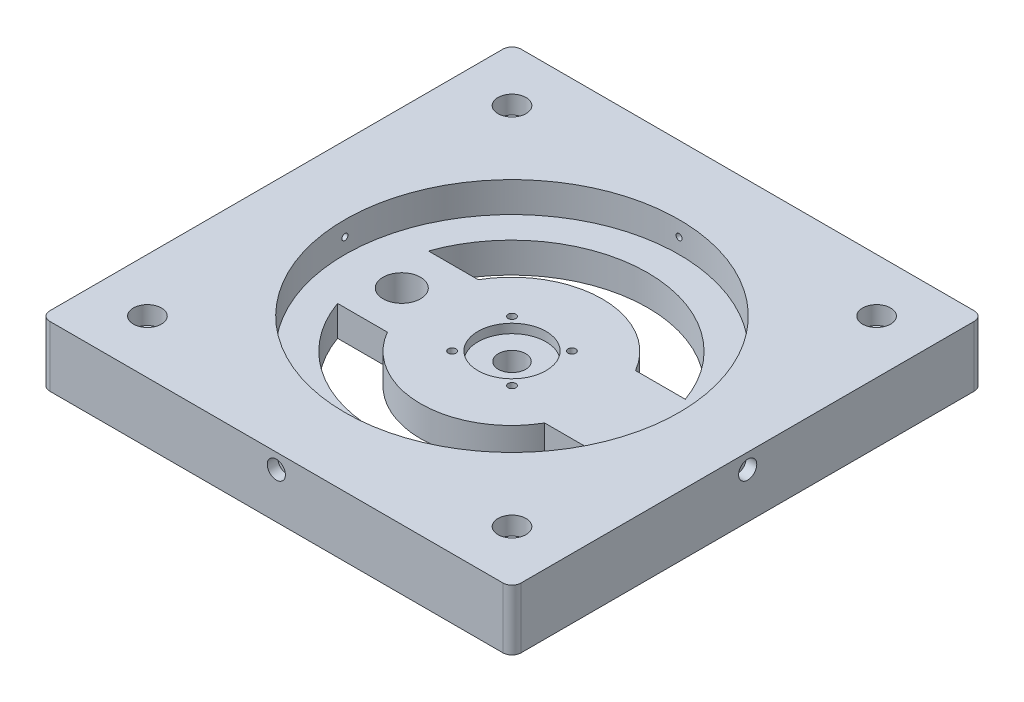
from build123d import *

# Parameters (mm, degrees)
SKETCH1_R           = 2.637642313
SKETCH1_R_2         = 73
BOSS_EXTRUDE1_DEPTH = 20
SKETCH7_R           = 73
SKETCH7_R_2         = 52.25
BOSS_EXTRUDE2_DEPTH = 10
SKETCH8_R           = 73
BOSS_EXTRUDE3_DEPTH = 10
SKETCH9_R           = 11.25
CUT_EXTRUDE1_DEPTH  = 3
SKETCH10_R          = 4.5
CUT_EXTRUDE2_DEPTH  = 89
SKETCH11_R          = 55.2
SKETCH11_R_2        = 52.25
CUT_EXTRUDE3_DEPTH  = 10
SKETCH12_R          = 1
CUT_EXTRUDE4_DEPTH  = 224
SKETCH13_R          = 1
CUT_EXTRUDE5_DEPTH  = 224
SKETCH14_R          = 2.637642313
SKETCH14_R_2        = 1.637642313
BOSS_EXTRUDE4_DEPTH = 20
SKETCH16_R          = 4.637642313
SKETCH16_R_2        = 1.637642313
CUT_EXTRUDE7_DEPTH  = 6
CUT_EXTRUDE11_DEPTH = 15.5
SKETCH19_R          = 6.2
CUT_EXTRUDE12_DEPTH = 144
SKETCH20_R          = 3
SKETCH20_R_2        = 1
CUT_EXTRUDE13_DEPTH = 3.5
SKETCH21_R          = 3
CUT_EXTRUDE14_DEPTH = 3.5
SKETCH22_R          = 3
SKETCH22_R_2        = 1
CUT_EXTRUDE15_DEPTH = 3.5
SKETCH23_R          = 3
CUT_EXTRUDE16_DEPTH = 3.5


with BuildPart() as part:
    # Sketch1 → Boss-Extrude1 (new body)
    with BuildSketch(Plane(origin=(0, 0, 0), x_dir=(1, 0, 0), z_dir=(0, 1, 0))):
        with BuildLine():
            Line((77.460838348, -75.098177713), (77.460838348, 74.577424045))
            ThreePointArc((77.460838348, 74.577424045), (76.578174547, 76.708362964), (74.447235628, 77.591026765))
            Line((74.447235628, 77.591026765), (-75.22836613, 77.591026765))
            ThreePointArc((-75.22836613, 77.591026765), (-77.359305049, 76.708362964), (-78.24196885, 74.577424045))
            Line((-78.24196885, 74.577424045), (-78.24196885, -75.098177713))
            ThreePointArc((-78.24196885, -75.098177713), (-77.359305049, -77.229116632), (-75.22836613, -78.111780433))
            Line((-75.22836613, -78.111780433), (74.447235628, -78.111780433))
            ThreePointArc((74.447235628, -78.111780433), (76.578174547, -77.229116632), (77.460838348, -75.098177713))
        make_face()
        with Locations((-60.604326536, -60.47413812)):
            Circle(SKETCH1_R, mode=Mode.SUBTRACT)
        with Locations((-60.604326536, 59.953384452)):
            Circle(SKETCH1_R, mode=Mode.SUBTRACT)
        with Locations((59.823196035, 59.953384452)):
            Circle(SKETCH1_R, mode=Mode.SUBTRACT)
        with Locations((59.823196035, -60.47413812)):
            Circle(SKETCH1_R, mode=Mode.SUBTRACT)
        with Locations((-0.390565251, -0.260376834)):
            Circle(SKETCH1_R_2, mode=Mode.SUBTRACT)
    extrude(amount=BOSS_EXTRUDE1_DEPTH)

    # Sketch7 → Boss-Extrude2 (add)
    with BuildSketch(Plane(origin=(0, 20, 0), x_dir=(1, 0, 0), z_dir=(0, 1, 0))):
        with Locations((-0.390565251, -0.260376834)):
            Circle(SKETCH7_R)
        with Locations((-0.390565251, -0.260376834)):
            Circle(SKETCH7_R_2, mode=Mode.SUBTRACT)
    extrude(amount=-BOSS_EXTRUDE2_DEPTH)

    # Sketch8 → Boss-Extrude3 (add)
    with BuildSketch(Plane.XZ.offset(-10)):
        with Locations((-0.390565251, 0.260376834)):
            Circle(SKETCH8_R)
    extrude(amount=BOSS_EXTRUDE3_DEPTH)

    # Sketch9 → Cut-Extrude1 (cut)
    with BuildSketch(Plane(origin=(0, 10, 0), x_dir=(1, 0, 0), z_dir=(0, 1, 0))):
        with Locations((-0.390565251, -0.260376834)):
            Circle(SKETCH9_R)
    extrude(amount=-CUT_EXTRUDE1_DEPTH, mode=Mode.SUBTRACT)

    # Sketch10 → Cut-Extrude2 (cut)
    with BuildSketch(Plane(origin=(0, 10, 0), x_dir=(1, 0, 0), z_dir=(0, 1, 0))):
        with Locations((-0.390565251, -0.260376834)):
            Circle(SKETCH10_R)
        with BuildLine():
            ThreePointArc((9.508929686, -11.424371771), (10.773429686, -10.159871771), (9.508929686, -8.895371771))
            ThreePointArc((9.508929686, -8.895371771), (8.244429686, -10.159871771), (9.508929686, -11.424371771))
        make_face()
        with BuildLine():
            ThreePointArc((-10.290060188, -11.424371771), (-9.025560188, -10.159871771), (-10.290060188, -8.895371771))
            ThreePointArc((-10.290060188, -8.895371771), (-11.554560188, -10.159871771), (-10.290060188, -11.424371771))
        make_face()
        with BuildLine():
            ThreePointArc((-10.290060188, 10.903618103), (-11.554560188, 9.639118103), (-10.290060188, 8.374618103))
            ThreePointArc((-10.290060188, 8.374618103), (-9.025560188, 9.639118103), (-10.290060188, 10.903618103))
        make_face()
        with BuildLine():
            ThreePointArc((9.508929686, 10.903618103), (8.244429686, 9.639118103), (9.508929686, 8.374618103))
            ThreePointArc((9.508929686, 8.374618103), (10.773429686, 9.639118103), (9.508929686, 10.903618103))
        make_face()
    extrude(amount=-CUT_EXTRUDE2_DEPTH, mode=Mode.SUBTRACT)

    # Sketch11 → Cut-Extrude3 (cut)
    with BuildSketch(Plane(origin=(0, 20, 0), x_dir=(1, 0, 0), z_dir=(0, 1, 0))):
        with Locations((-0.390565251, -0.260376834)):
            Circle(SKETCH11_R)
        with Locations((-0.390565251, -0.260376834)):
            Circle(SKETCH11_R_2, mode=Mode.SUBTRACT)
    extrude(amount=-CUT_EXTRUDE3_DEPTH, mode=Mode.SUBTRACT)

    # Sketch12 → Cut-Extrude4 (cut)
    with BuildSketch(Plane(origin=(0, 0, -77.591026765), x_dir=(-1, 0, 0), z_dir=(0, 0, -1))):
        with Locations((0.390565251, 15)):
            Circle(SKETCH12_R)
    extrude(amount=-CUT_EXTRUDE4_DEPTH, mode=Mode.SUBTRACT)

    # Sketch13 → Cut-Extrude5 (cut)
    with BuildSketch(Plane.ZY.offset(78.24196885)):
        with Locations((0.260376834, 15)):
            Circle(SKETCH13_R)
    extrude(amount=-CUT_EXTRUDE5_DEPTH, mode=Mode.SUBTRACT)

    # Sketch14 → Boss-Extrude4 (add)
    with BuildSketch(Plane(origin=(0, 20, 0), x_dir=(1, 0, 0), z_dir=(0, 1, 0))):
        with Locations((59.823196035, -60.47413812)):
            Circle(SKETCH14_R)
        with Locations((59.823196035, -60.47413812)):
            Circle(SKETCH14_R_2, mode=Mode.SUBTRACT)
        with Locations((-60.604326536, -60.47413812)):
            Circle(SKETCH14_R)
        with Locations((-60.604326536, -60.47413812)):
            Circle(SKETCH14_R_2, mode=Mode.SUBTRACT)
        with Locations((-60.604326536, 59.953384452)):
            Circle(SKETCH14_R)
        with Locations((-60.604326536, 59.953384452)):
            Circle(SKETCH14_R_2, mode=Mode.SUBTRACT)
        with Locations((59.823196035, 59.953384452)):
            Circle(SKETCH14_R)
        with Locations((59.823196035, 59.953384452)):
            Circle(SKETCH14_R_2, mode=Mode.SUBTRACT)
    extrude(amount=-BOSS_EXTRUDE4_DEPTH)

    # Sketch16 → Cut-Extrude7 (cut)
    with BuildSketch(Plane(origin=(0, 20, 0), x_dir=(1, 0, 0), z_dir=(0, 1, 0))):
        with Locations((59.823196035, -60.47413812)):
            Circle(SKETCH16_R)
        with Locations((59.823196035, -60.47413812)):
            Circle(SKETCH16_R_2, mode=Mode.SUBTRACT)
        with Locations((-60.604326536, -60.47413812)):
            Circle(SKETCH16_R)
        with Locations((-60.604326536, -60.47413812)):
            Circle(SKETCH16_R_2, mode=Mode.SUBTRACT)
        with Locations((-60.604326536, 59.953384452)):
            Circle(SKETCH16_R)
        with Locations((-60.604326536, 59.953384452)):
            Circle(SKETCH16_R_2, mode=Mode.SUBTRACT)
        with Locations((59.823196035, 59.953384452)):
            Circle(SKETCH16_R)
        with Locations((59.823196035, 59.953384452)):
            Circle(SKETCH16_R_2, mode=Mode.SUBTRACT)
    extrude(amount=-CUT_EXTRUDE7_DEPTH, mode=Mode.SUBTRACT)

    # Sketch17 → Cut-Extrude11 (cut)
    with BuildSketch(Plane(origin=(0, 10, 0), x_dir=(1, 0, 0), z_dir=(0, 1, 0))):
        with BuildLine():
            ThreePointArc((42.03584162, 14.549614415), (-0.390565251, 44.549614415), (-42.816972122, 14.549614415))
            Line((-42.816972122, 14.549614415), (-26.371327364, 14.549614415))
            ThreePointArc((-26.371327364, 14.549614415), (-0.390565251, 29.549614415), (25.590196863, 14.549614415))
            Line((25.590196863, 14.549614415), (42.03584162, 14.549614415))
        make_face()
        with BuildLine():
            Line((-26.371327364, -15.450385585), (-42.816972122, -15.450385585))
            ThreePointArc((-42.816972122, -15.450385585), (-0.390565251, -45.450385585), (42.03584162, -15.450385585))
            Line((42.03584162, -15.450385585), (25.590196863, -15.450385585))
            ThreePointArc((25.590196863, -15.450385585), (-0.390565251, -30.450385585), (-26.371327364, -15.450385585))
        make_face()
    extrude(amount=-CUT_EXTRUDE11_DEPTH, mode=Mode.SUBTRACT)

    # Sketch19 → Cut-Extrude12 (cut)
    with BuildSketch(Plane(origin=(0, 10, 0), x_dir=(1, 0, 0), z_dir=(0, 1, 0))):
        with Locations((-36.610454512, -0.450385585)):
            Circle(SKETCH19_R)
    extrude(amount=-CUT_EXTRUDE12_DEPTH, mode=Mode.SUBTRACT)

    # Sketch20 → Cut-Extrude13 (cut)
    with BuildSketch(Plane.ZY.offset(78.24196885)):
        with Locations((0.260376834, 15)):
            Circle(SKETCH20_R)
        with Locations((0.260376834, 15)):
            Circle(SKETCH20_R_2, mode=Mode.SUBTRACT)
    extrude(amount=-CUT_EXTRUDE13_DEPTH, mode=Mode.SUBTRACT)

    # Sketch21 → Cut-Extrude14 (cut)
    with BuildSketch(Plane.XY.offset(78.111780433)):
        with Locations((-0.390565251, 15)):
            Circle(SKETCH21_R)
    extrude(amount=-CUT_EXTRUDE14_DEPTH, mode=Mode.SUBTRACT)

    # Sketch22 → Cut-Extrude15 (cut)
    with BuildSketch(Plane(origin=(77.460838348, 0, 0), x_dir=(0, 0, -1), z_dir=(1, 0, 0))):
        with Locations((-0.260376834, 15)):
            Circle(SKETCH22_R)
        with Locations((-0.260376834, 15)):
            Circle(SKETCH22_R_2, mode=Mode.SUBTRACT)
    extrude(amount=-CUT_EXTRUDE15_DEPTH, mode=Mode.SUBTRACT)

    # Sketch23 → Cut-Extrude16 (cut)
    with BuildSketch(Plane(origin=(0, 0, -77.591026765), x_dir=(-1, 0, 0), z_dir=(0, 0, -1))):
        with Locations((0.390565251, 15)):
            Circle(SKETCH23_R)
    extrude(amount=-CUT_EXTRUDE16_DEPTH, mode=Mode.SUBTRACT)


solid = part.part
